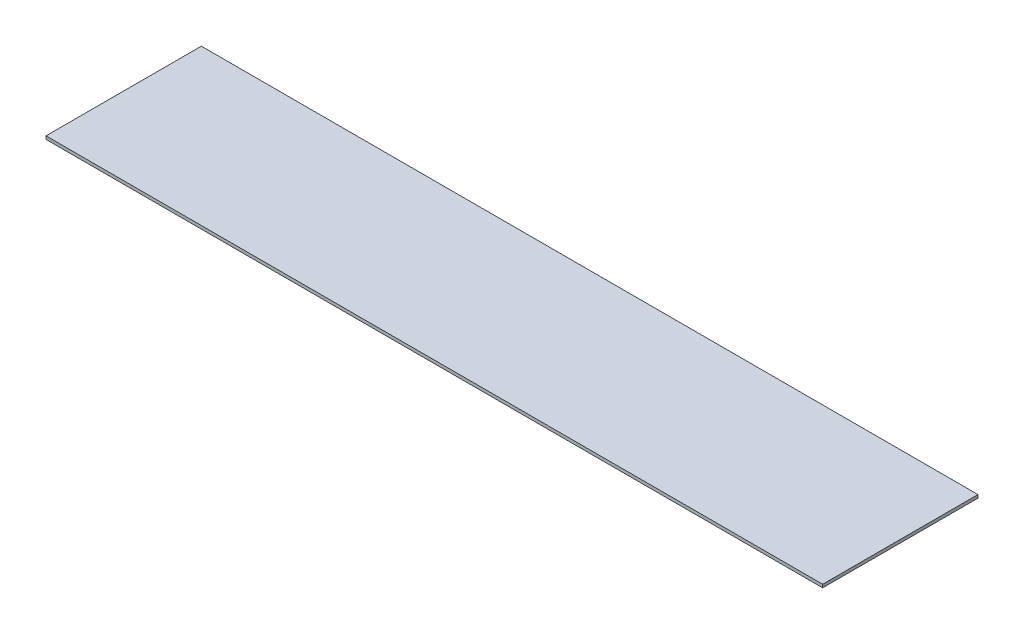
from build123d import *

# Parameters (mm, degrees)
CROQUIS1_W              = 50
CROQUIS1_H              = 10
SALIENTE_EXTRUIR1_DEPTH = 0.2


with BuildPart() as part:
    # Croquis1 → Saliente-Extruir1 (new body)
    with BuildSketch(Plane(origin=(0, 0, 0), x_dir=(1, 0, 0), z_dir=(0, 1, 0))):
        Rectangle(CROQUIS1_W, CROQUIS1_H)
    extrude(amount=SALIENTE_EXTRUIR1_DEPTH)


solid = part.part
